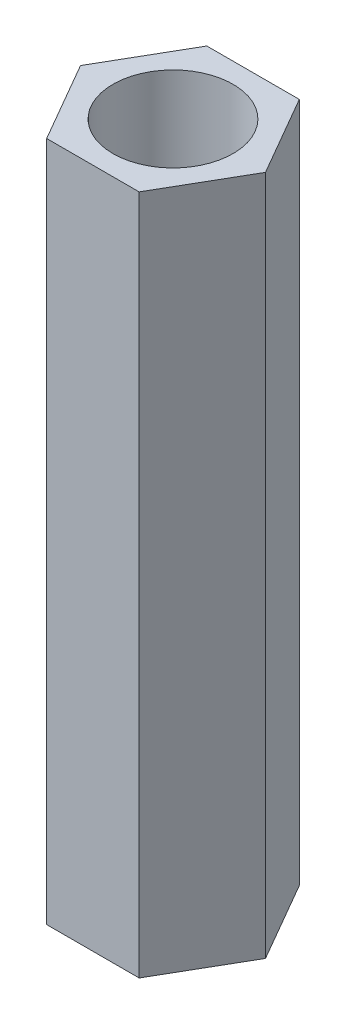
from build123d import *

# Parameters (mm, degrees)
CROQUIS1_R              = 1.5
SALIENTE_EXTRUIR1_DEPTH = 8.5


with BuildPart() as part:
    # Croquis1 → Saliente-Extruir1 (new body, symmetric)
    with BuildSketch(Plane(origin=(0, 0, 0), x_dir=(1, 0, 0), z_dir=(0, 1, 0))):
        Polygon((1.154700538, 2), (-1.154700538, 2), (-2.309401077, 0), (-1.154700538, -2), (1.154700538, -2), (2.309401077, 0), align=None)
        Circle(CROQUIS1_R, mode=Mode.SUBTRACT)
    extrude(amount=SALIENTE_EXTRUIR1_DEPTH, both=True)


solid = part.part
